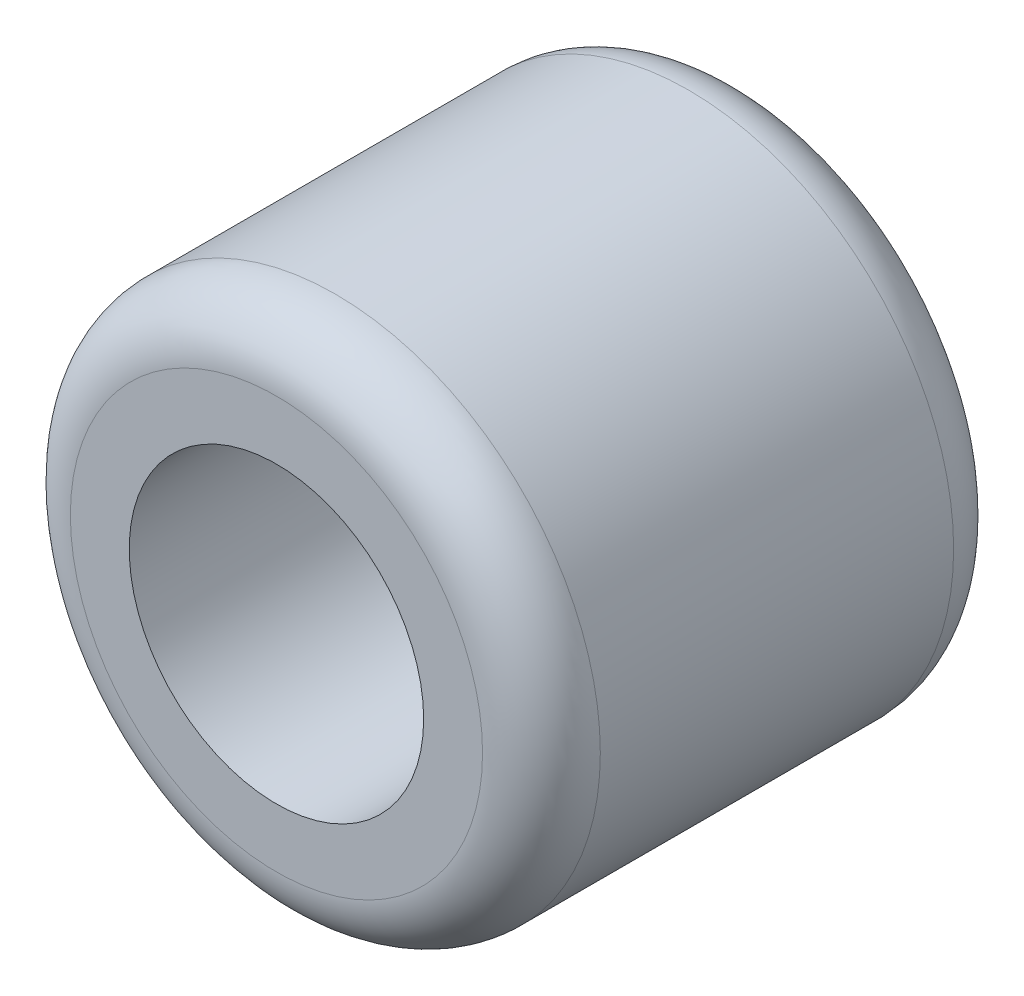
from build123d import *

# Parameters (mm, degrees)
SKETCH1_R           = 4.5
SKETCH1_R_2         = 2.5
BOSS_EXTRUDE1_DEPTH = 8
FILLET1_R           = 1


with BuildPart() as part:
    # Sketch1 → Boss-Extrude1 (new body)
    with BuildSketch(Plane.XY):
        Circle(SKETCH1_R)
        Circle(SKETCH1_R_2, mode=Mode.SUBTRACT)
    extrude(amount=BOSS_EXTRUDE1_DEPTH)

    # Fillet1
    fillet1_edges = [part.edges().sort_by_distance(p)[0] for p in [
        (-4.5, 0, 0),
        (-4.5, 0, 8),
    ]]
    fillet(fillet1_edges, radius=FILLET1_R)


solid = part.part
